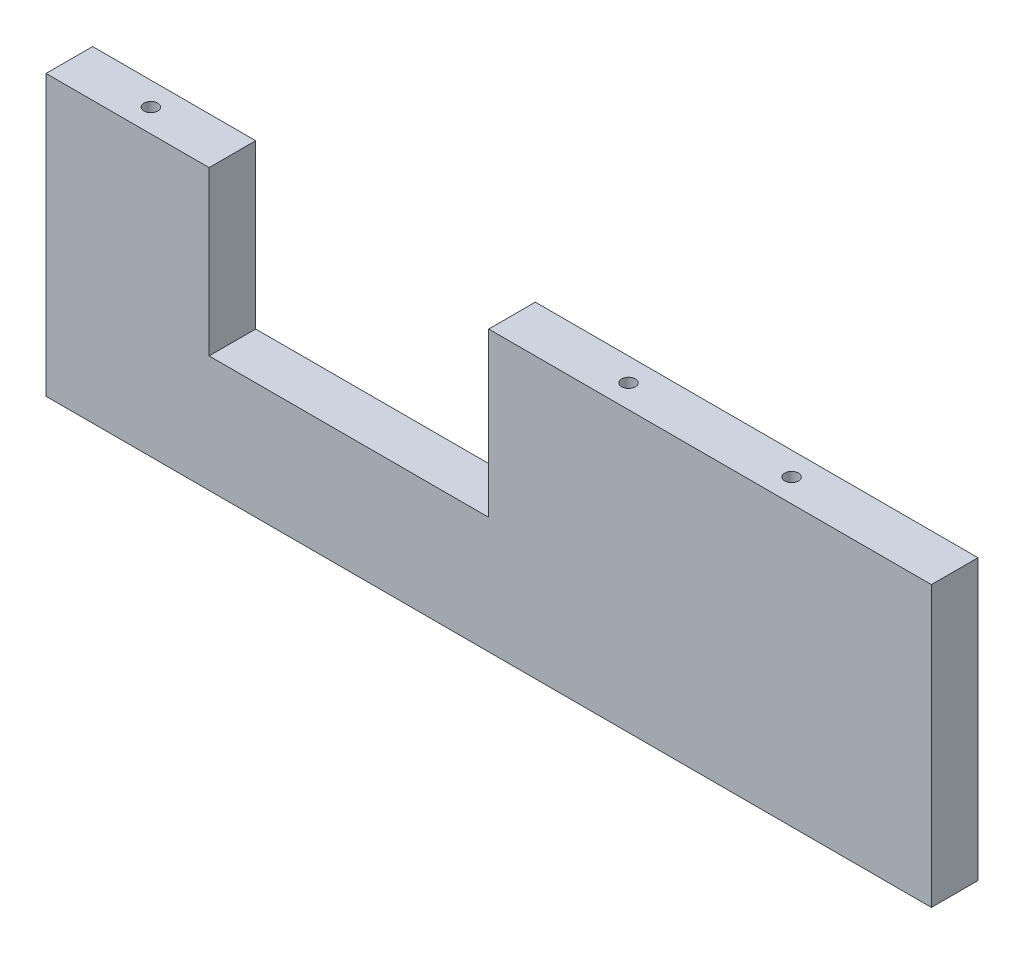
from build123d import *

# Parameters (mm, degrees)
BOSS_EXTRUDE1_DEPTH = 10
CUT_EXTRUDE1_DEPTH  = 61


with BuildPart() as part:
    # Sketch2 → Boss-Extrude1 (new body)
    with BuildSketch(Plane.XY):
        Polygon((-60, 30), (-95, 30), (-95, -30), (95, -30), (95, 30), (0, 30), (0, -5), (-60, -5), align=None)
    extrude(amount=BOSS_EXTRUDE1_DEPTH)

    # Sketch3 → Cut-Extrude1 (cut, through all)
    with BuildSketch(Plane(origin=(0, 30, 0), x_dir=(1, 0, 0), z_dir=(0, 1, 0))):
        with BuildLine():
            ThreePointArc((-78.975, -5), (-77.5, -6.475), (-76.025, -5))
            Line((-76.025, -5), (-78.975, -5))
        make_face()
        with BuildLine():
            Line((-78.975, -5), (-76.025, -5))
            ThreePointArc((-76.025, -5), (-77.5, -3.525), (-78.975, -5))
        make_face()
        with BuildLine():
            ThreePointArc((58.525, -5), (60, -6.475), (61.475, -5))
            Line((61.475, -5), (58.525, -5))
        make_face()
        with BuildLine():
            Line((58.525, -5), (61.475, -5))
            ThreePointArc((61.475, -5), (60, -3.525), (58.525, -5))
        make_face()
        with BuildLine():
            ThreePointArc((23.525, -5), (25, -6.475), (26.475, -5))
            Line((26.475, -5), (23.525, -5))
        make_face()
        with BuildLine():
            Line((23.525, -5), (26.475, -5))
            ThreePointArc((26.475, -5), (25, -3.525), (23.525, -5))
        make_face()
    extrude(amount=-CUT_EXTRUDE1_DEPTH, mode=Mode.SUBTRACT)


solid = part.part
